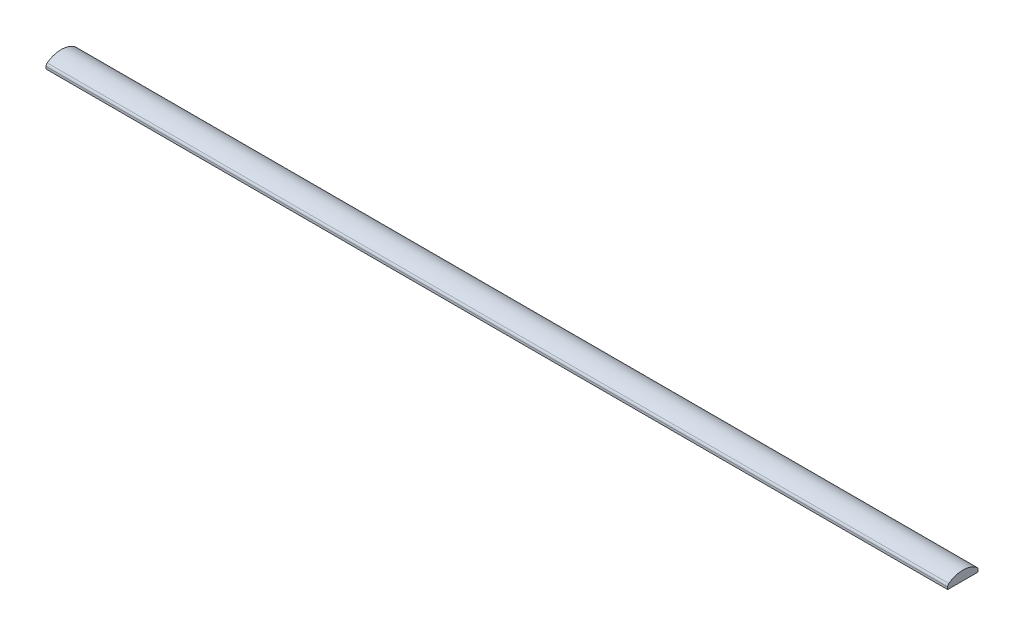
from build123d import *

# Parameters (mm, degrees)
BOSS_EXTRUDE1_DEPTH = 150


with BuildPart() as part:
    # Sketch1 → Boss-Extrude1 (new body, symmetric)
    with BuildSketch(Plane(origin=(0, 0, 0), x_dir=(0, 0, -1), z_dir=(1, 0, 0))):
        with BuildLine():
            Line((-5.05, -0.625), (5.05, -0.625))
            Line((5.05, -0.625), (5.05, 0.141657769))
            ThreePointArc((5.05, 0.141657769), (4.942763552, 0.592183285), (4.644053518, 0.946083289))
            ThreePointArc((4.644053518, 0.946083289), (0, 2.475), (-4.644053518, 0.946083289))
            ThreePointArc((-4.644053518, 0.946083289), (-4.942763552, 0.592183285), (-5.05, 0.141657769))
            Line((-5.05, 0.141657769), (-5.05, -0.625))
        make_face()
    extrude(amount=BOSS_EXTRUDE1_DEPTH, both=True)


solid = part.part
